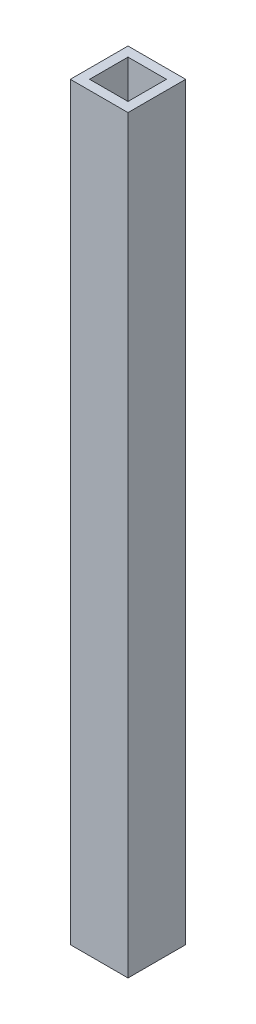
from build123d import *

# Parameters (mm, degrees)
SKETCH1_W           = 30
SKETCH1_H           = 30
SKETCH1_W_2         = 20
SKETCH1_H_2         = 20
BOSS_EXTRUDE1_DEPTH = 390


with BuildPart() as part:
    # Sketch1 → Boss-Extrude1 (new body)
    with BuildSketch(Plane(origin=(0, 0, 0), x_dir=(1, 0, 0), z_dir=(0, 1, 0))):
        with Locations((15, 15)):
            Rectangle(SKETCH1_W, SKETCH1_H)
        with Locations((15, 15)):
            Rectangle(SKETCH1_W_2, SKETCH1_H_2, mode=Mode.SUBTRACT)
    extrude(amount=BOSS_EXTRUDE1_DEPTH)


solid = part.part
